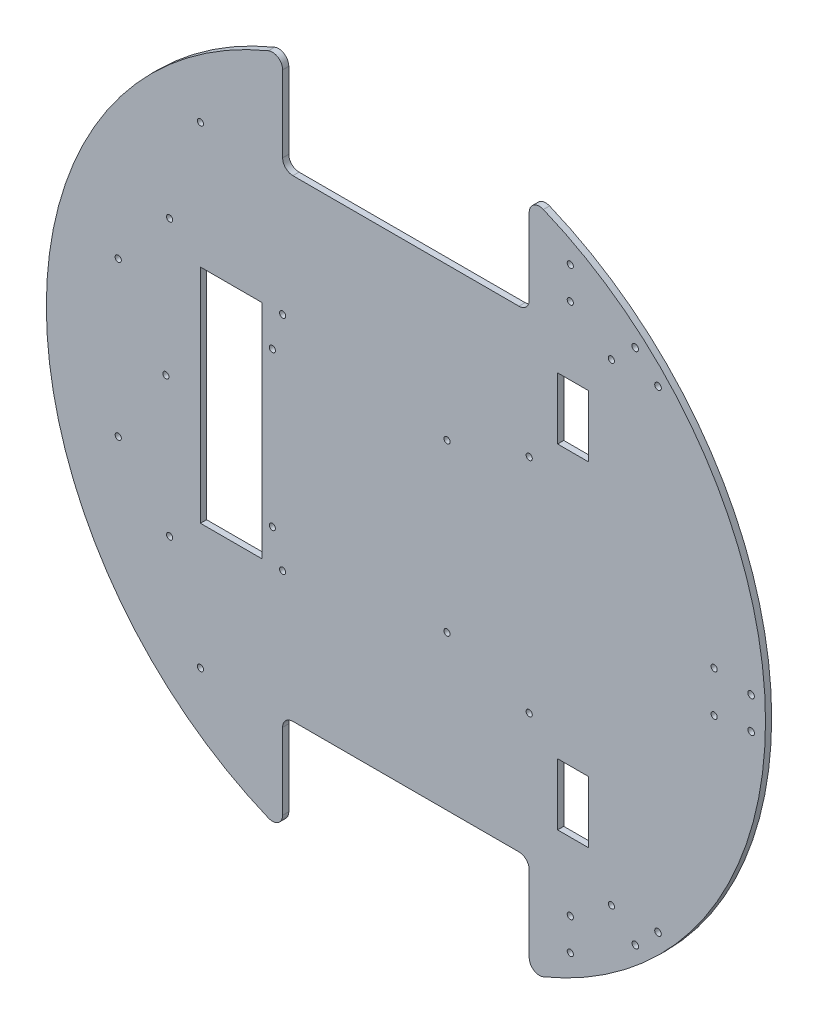
from build123d import *

# Parameters (mm, degrees)
SKETCH_1_R           = 175
EXTRUDE_1_DEPTH      = 3
CUT_EXTRUDE_1_DEPTH  = 3
FILLET_1_R           = 5
FILLET_2_R           = 5
FILLET_3_R           = 5
SKETCH_5_R           = 1.5
CUT_EXTRUDE_4_DEPTH  = 3
SKETCH_6_R           = 1.5
CUT_EXTRUDE_5_DEPTH  = 3
SKETCH_7_W           = 30
SKETCH_7_H           = 108
CUT_EXTRUDE_6_DEPTH  = 3
SKETCH_8_R           = 1.5
CUT_EXTRUDE_7_DEPTH  = 3
SKETCH_9_R           = 1.5
CUT_EXTRUDE_8_DEPTH  = 10
SKETCH_10_R          = 1.6
CUT_EXTRUDE_9_DEPTH  = 10
SKETCH_11_W          = 15
SKETCH_11_H          = 30
CUT_EXTRUDE_10_DEPTH = 10
SKETCH_22_R          = 1.5
CUT_EXTRUDE_11_DEPTH = 10
SKETCH_23_R          = 1.5
CUT_EXTRUDE_12_DEPTH = 10


with BuildPart() as part:
    # ｽｹｯﾁ1 → ﾎﾞｽ - 押し出し1 (new body)
    with BuildSketch(Plane.XY):
        Circle(SKETCH_1_R)
    extrude(amount=EXTRUDE_1_DEPTH)

    # ｽｹｯﾁ2 → ｶｯﾄ - 押し出し1 (cut)
    with BuildSketch(Plane.XY.offset(3)):
        with BuildLine():
            Line((-60, 115), (0, 115))
            Line((0, 115), (0, 175))
            ThreePointArc((0, 175), (-30.465194158, 172.327803749), (-60, 164.392822228))
            Line((-60, 164.392822228), (-60, 115))
        make_face()
        with BuildLine():
            Line((0, 175), (0, 115))
            Line((0, 115), (60, 115))
            Line((60, 115), (60, 164.392822228))
            ThreePointArc((60, 164.392822228), (30.465194158, 172.327803749), (0, 175))
        make_face()
        with BuildLine():
            Line((0, -175), (0, -115))
            Line((0, -115), (-60, -115))
            Line((-60, -115), (-60, -164.392822228))
            ThreePointArc((-60, -164.392822228), (-30.465194158, -172.327803749), (0, -175))
        make_face()
        with BuildLine():
            Line((60, -115), (0, -115))
            Line((0, -115), (0, -175))
            ThreePointArc((0, -175), (30.465194158, -172.327803749), (60, -164.392822228))
            Line((60, -164.392822228), (60, -115))
        make_face()
    extrude(amount=-CUT_EXTRUDE_1_DEPTH, mode=Mode.SUBTRACT)

    # ﾌｨﾚｯﾄ1
    fillet_1_edges = [part.edges().sort_by_distance(p)[0] for p in [
        (-60, 164.392822228, 1.5),
    ]]
    fillet(fillet_1_edges, radius=FILLET_1_R)

    # ﾌｨﾚｯﾄ2
    fillet_2_edges = [part.edges().sort_by_distance(p)[0] for p in [
        (-60, 115, 1.5),
        (60, 164.392822228, 1.5),
        (60, 115, 1.5),
    ]]
    fillet(fillet_2_edges, radius=FILLET_2_R)

    # ﾌｨﾚｯﾄ3
    fillet_3_edges = [part.edges().sort_by_distance(p)[0] for p in [
        (-60, -115, 1.5),
        (60, -115, 1.5),
        (60, -164.392822228, 1.5),
        (-60, -164.392822228, 1.5),
    ]]
    fillet(fillet_3_edges, radius=FILLET_3_R)

    # ｽｹｯﾁ5 → ｶｯﾄ - 押し出し4 (cut)
    with BuildSketch(Plane.XY.offset(3)):
        with Locations((-100, -115)):
            Circle(SKETCH_5_R)
        with Locations((100, -115)):
            Circle(SKETCH_5_R)
        with Locations((100, 115)):
            Circle(SKETCH_5_R)
        with Locations((-100, 115)):
            Circle(SKETCH_5_R)
    extrude(amount=-CUT_EXTRUDE_4_DEPTH, mode=Mode.SUBTRACT)

    # ｽｹｯﾁ6 → ｶｯﾄ - 押し出し5 (cut)
    with BuildSketch(Plane.XY.offset(3)):
        with Locations((-60, 54)):
            Circle(SKETCH_6_R)
        with Locations((60, 54)):
            Circle(SKETCH_6_R)
        with Locations((-60, -54)):
            Circle(SKETCH_6_R)
        with Locations((60, -54)):
            Circle(SKETCH_6_R)
    extrude(amount=-CUT_EXTRUDE_5_DEPTH, mode=Mode.SUBTRACT)

    # ｽｹｯﾁ7 → ｶｯﾄ - 押し出し6 (cut)
    with BuildSketch(Plane.XY.offset(3)):
        with Locations((-85, 0)):
            Rectangle(SKETCH_7_W, SKETCH_7_H)
    extrude(amount=-CUT_EXTRUDE_6_DEPTH, mode=Mode.SUBTRACT)

    # ｽｹｯﾁ8 → ｶｯﾄ - 押し出し7 (cut)
    with BuildSketch(Plane.XY.offset(3)):
        with Locations((-115, -67)):
            Circle(SKETCH_8_R)
        with Locations((-116.822468618, 0)):
            Circle(SKETCH_8_R)
        with Locations((-115, 67)):
            Circle(SKETCH_8_R)
    extrude(amount=-CUT_EXTRUDE_7_DEPTH, mode=Mode.SUBTRACT)

    # ｽｹｯﾁ9 → ｶｯﾄ - 押し出し8 (cut)
    with BuildSketch(Plane.XY.offset(3)):
        with Locations((-65, 37)):
            Circle(SKETCH_9_R)
        with Locations((20, 41)):
            Circle(SKETCH_9_R)
        with Locations((-65, -38)):
            Circle(SKETCH_9_R)
        with Locations((20, -40)):
            Circle(SKETCH_9_R)
    extrude(amount=-CUT_EXTRUDE_8_DEPTH, mode=Mode.SUBTRACT)

    # ｽｹｯﾁ10 → ｶｯﾄ - 押し出し9 (cut)
    with BuildSketch(Plane.XY.offset(3)):
        with Locations((111.643659725, -125.921059639)):
            Circle(SKETCH_10_R)
        with Locations((122.679794489, -115.037952538)):
            Circle(SKETCH_10_R)
        with Locations((168, 7.75)):
            Circle(SKETCH_10_R)
        with Locations((168, -7.75)):
            Circle(SKETCH_10_R)
        with Locations((111.56768007, 125.844011632)):
            Circle(SKETCH_10_R)
        with Locations((122.679794489, 115.037952538)):
            Circle(SKETCH_10_R)
    extrude(amount=-CUT_EXTRUDE_9_DEPTH, mode=Mode.SUBTRACT)

    # ｽｹｯﾁ11 → ｶｯﾄ - 押し出し10 (cut)
    with BuildSketch(Plane.XY.offset(3)):
        with Locations((81.317279836, 81.317279836)):
            Rectangle(SKETCH_11_W, SKETCH_11_H)
        with Locations((81.317279836, -81.317279836)):
            Rectangle(SKETCH_11_W, SKETCH_11_H)
    extrude(amount=-CUT_EXTRUDE_10_DEPTH, mode=Mode.SUBTRACT)

    # ｽｹｯﾁ22 → ｶｯﾄ - 押し出し11 (cut)
    with BuildSketch(Plane.XY.offset(10)):
        with Locations((150, -10)):
            Circle(SKETCH_22_R)
        with Locations((150, 10)):
            Circle(SKETCH_22_R)
    extrude(amount=-CUT_EXTRUDE_11_DEPTH, mode=Mode.SUBTRACT)

    # ｽｹｯﾁ23 → ｶｯﾄ - 押し出し12 (cut)
    with BuildSketch(Plane.XY.offset(3)):
        with Locations((80, 145)):
            Circle(SKETCH_23_R)
        with Locations((80, 129.5)):
            Circle(SKETCH_23_R)
        with Locations((80, -129.5)):
            Circle(SKETCH_23_R)
        with Locations((80, -145)):
            Circle(SKETCH_23_R)
        with Locations((-140, 37.5)):
            Circle(SKETCH_23_R)
        with Locations((-140, -37.5)):
            Circle(SKETCH_23_R)
    extrude(amount=-CUT_EXTRUDE_12_DEPTH, mode=Mode.SUBTRACT)


solid = part.part
